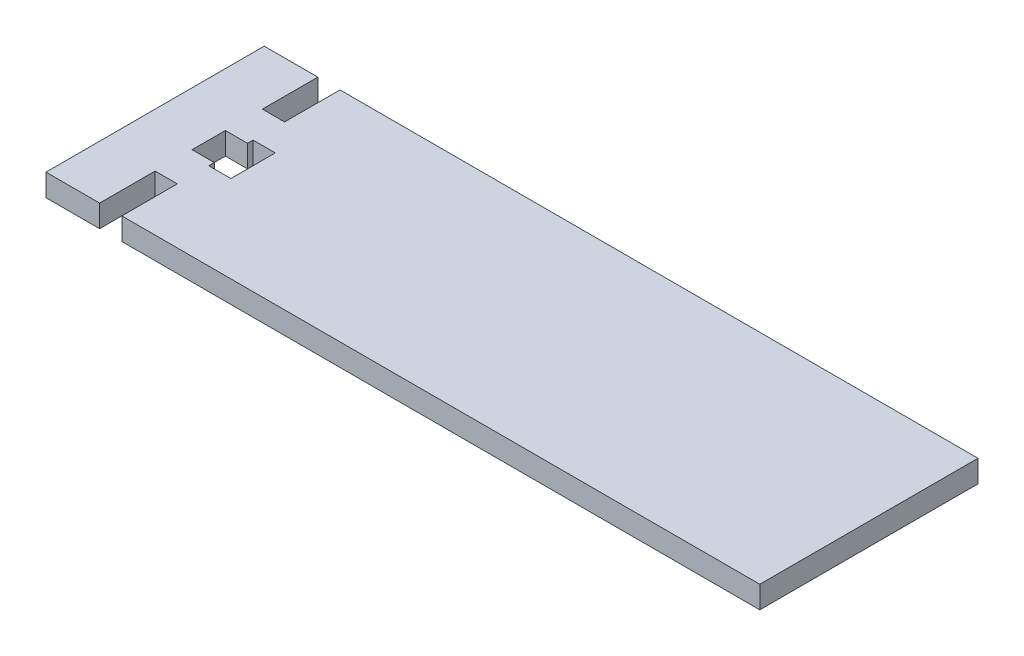
from build123d import *

# Parameters (mm, degrees)
SKETCH1_W           = 193
SKETCH1_H           = 59
BOSS_EXTRUDE1_DEPTH = 6
SKETCH3_W           = 6
SKETCH3_H           = 15
SKETCH3_H_2         = 9
SKETCH3_H_3         = 12
CUT_EXTRUDE1_DEPTH  = 7
SKETCH4_W           = 199.10755054
SKETCH4_H           = 40.828336107
CUT_EXTRUDE2_DEPTH  = 7


with BuildPart() as part:
    # Sketch1 → Boss-Extrude1 (new body)
    with BuildSketch(Plane(origin=(0, 0, 0), x_dir=(1, 0, 0), z_dir=(0, 1, 0))):
        Rectangle(SKETCH1_W, SKETCH1_H)
    extrude(amount=BOSS_EXTRUDE1_DEPTH)

    # Sketch3 → Cut-Extrude1 (cut, through all)
    with BuildSketch(Plane(origin=(0, 0, 0), x_dir=(-1, 0, 0), z_dir=(0, -1, 0))):
        with Locations((79, 22)):
            Rectangle(SKETCH3_W, SKETCH3_H)
        with Locations((79, -22)):
            Rectangle(SKETCH3_W, SKETCH3_H)
        with Locations((79, 0)):
            Rectangle(SKETCH3_W, SKETCH3_H_2)
        with Locations((73, 0)):
            Rectangle(SKETCH3_W, SKETCH3_H_3)
    extrude(amount=-CUT_EXTRUDE1_DEPTH, mode=Mode.SUBTRACT)

    # Sketch4 → Cut-Extrude2 (cut, through all)
    with BuildSketch(Plane.XZ):
        with Locations((-141.775997492, -49.914168053)):
            Rectangle(SKETCH4_W, SKETCH4_H)
        with Locations((-107.998219714, -49.914168053)):
            Rectangle(SKETCH4_W, SKETCH4_H)
    cut_extrude2 = extrude(amount=-CUT_EXTRUDE2_DEPTH, mode=Mode.SUBTRACT)

    # Mirror1: Cut-Extrude2 across plane
    add(cut_extrude2.mirror(Plane.XY), mode=Mode.SUBTRACT)

    # Mirror2: Cut-Extrude2 across plane
    add(cut_extrude2.mirror(Plane(origin=(0, 0, 0), x_dir=(0, 0, 1), z_dir=(1, 0, 0))), mode=Mode.SUBTRACT)


solid = part.part
